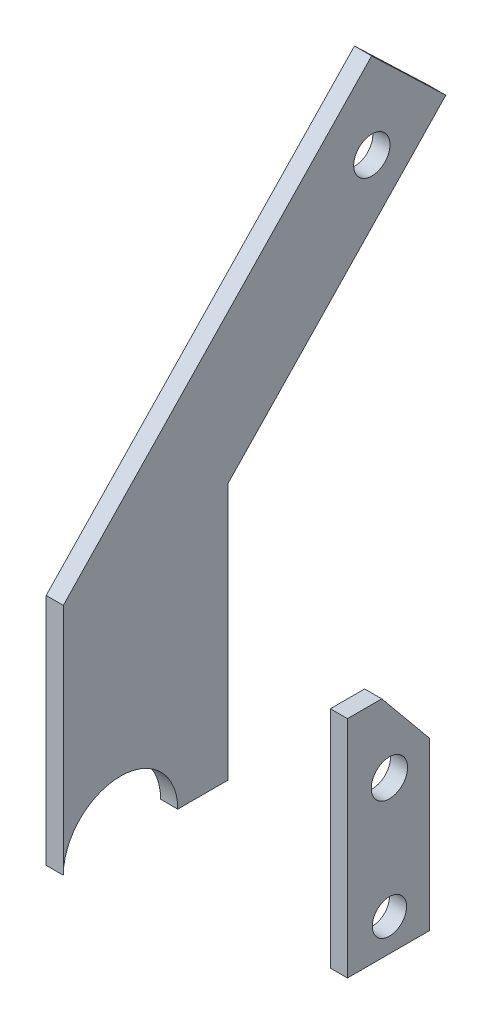
from build123d import *

# Parameters (mm, degrees)
CROQUIS1_R                = 5.3
SALIENTE_EXTRUIR1_DEPTH   = 5
CROQUIS1_R_2              = 5
SALIENTE_EXTRUIR1_2_DEPTH = 5


with BuildPart() as part:
    # Croquis1 → Saliente-Extruir1 (new body)
    with BuildSketch(Plane(origin=(0, 0, 0), x_dir=(0, 0, -1), z_dir=(1, 0, 0))):
        with BuildLine():
            Line((63.513171272, 141.30430007), (35.834565908, 112.427063272))
            Line((35.834565908, 112.427063272), (-0.021736706, 75.017991259))
            Line((-0.021736706, 75.017991259), (-0.021736706, 0.017991259))
            Line((-0.021736706, 0.017991259), (-14.69922376, 0.017991259))
            ThreePointArc((-14.69922376, 0.017991259), (-31.39972376, 16.718491259), (-48.10022376, 0.017991259))
            Line((-48.10022376, 0.017991259), (-48.10022376, 68.212234499))
            Line((-48.10022376, 68.212234499), (14.176638309, 133.186017295))
            Line((14.176638309, 133.186017295), (41.855243673, 162.063254093))
            Line((41.855243673, 162.063254093), (63.513171272, 141.30430007))
        make_face()
        with Locations((41.917193234, 136.985296196)):
            Circle(CROQUIS1_R, mode=Mode.SUBTRACT)
    extrude(amount=SALIENTE_EXTRUIR1_DEPTH)


with BuildPart() as body_2:
    # Croquis1 → Saliente-Extruir1 2 (new body)
    with BuildSketch(Plane(origin=(0, 0, 0), x_dir=(0, 0, -1), z_dir=(1, 0, 0))):
        Polygon((58.80261038, -67.395595521), (58.80261038, -18.837819707), (44.811911953, -1.859587834), (34.811911953, -1.859587834), (34.811911953, -67.395595521), align=None)
        with Locations((47.045373173, -22.932733847)):
            Circle(CROQUIS1_R, mode=Mode.SUBTRACT)
        with Locations((47.045373173, -57.944775054)):
            Circle(CROQUIS1_R_2, mode=Mode.SUBTRACT)
    extrude(amount=SALIENTE_EXTRUIR1_2_DEPTH)


solid = Compound([part.part, body_2.part])
